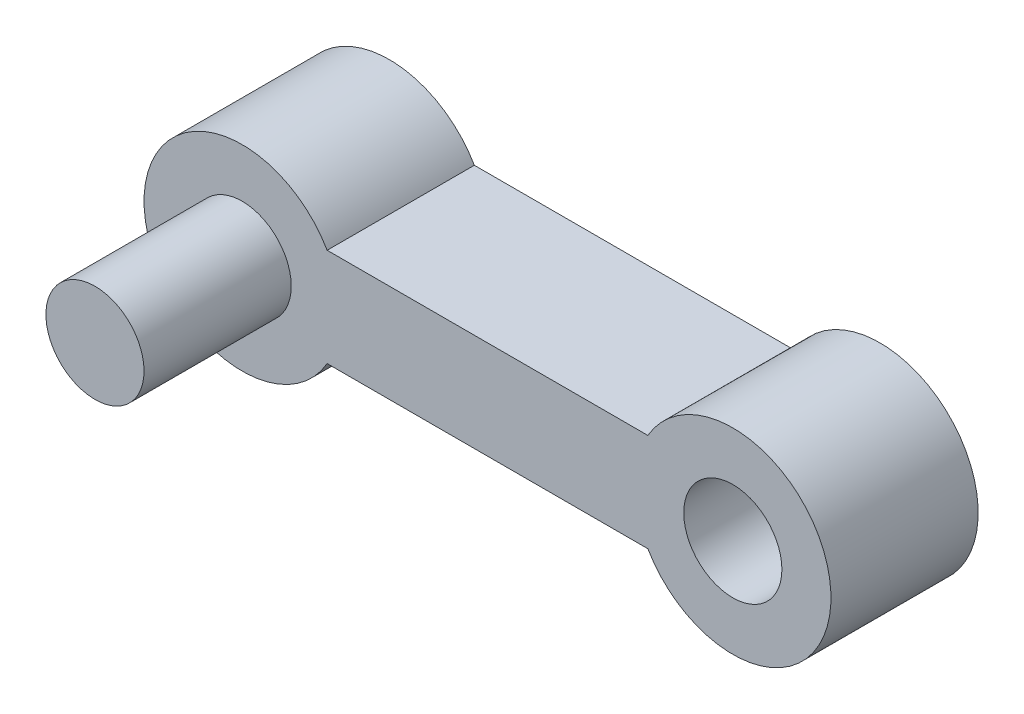
from build123d import *

# Parameters (mm, degrees)
BOSS_EXTRUDE1_DEPTH = 3
SKETCH3_R           = 1
BOSS_EXTRUDE2_DEPTH = 3
SKETCH4_R           = 1
CUT_EXTRUDE1_DEPTH  = 3


with BuildPart() as part:
    # Sketch2 → Boss-Extrude1 (new body)
    with BuildSketch(Plane.XY):
        with BuildLine():
            Line((-36.5050045, 13.800340042), (-29.969106115, 13.800340042))
            ThreePointArc((-29.969106115, 13.800340042), (-26.237055307, 12.800340042), (-29.969106115, 11.800340042))
            Line((-29.969106115, 11.800340042), (-36.5050045, 11.800340042))
            ThreePointArc((-36.5050045, 11.800340042), (-40.237055307, 12.800340042), (-36.5050045, 13.800340042))
        make_face()
    extrude(amount=BOSS_EXTRUDE1_DEPTH)

    # Sketch3 → Boss-Extrude2 (add)
    with BuildSketch(Plane.XY.offset(3)):
        with Locations((-38.237055307, 12.800340042)):
            Circle(SKETCH3_R)
    extrude(amount=BOSS_EXTRUDE2_DEPTH)

    # Sketch4 → Cut-Extrude1 (cut)
    with BuildSketch(Plane(origin=(0, 0, 0), x_dir=(-1, 0, 0), z_dir=(0, 0, -1))):
        with Locations((28.237055307, 12.800340042)):
            Circle(SKETCH4_R)
    extrude(amount=-CUT_EXTRUDE1_DEPTH, mode=Mode.SUBTRACT)


solid = part.part
